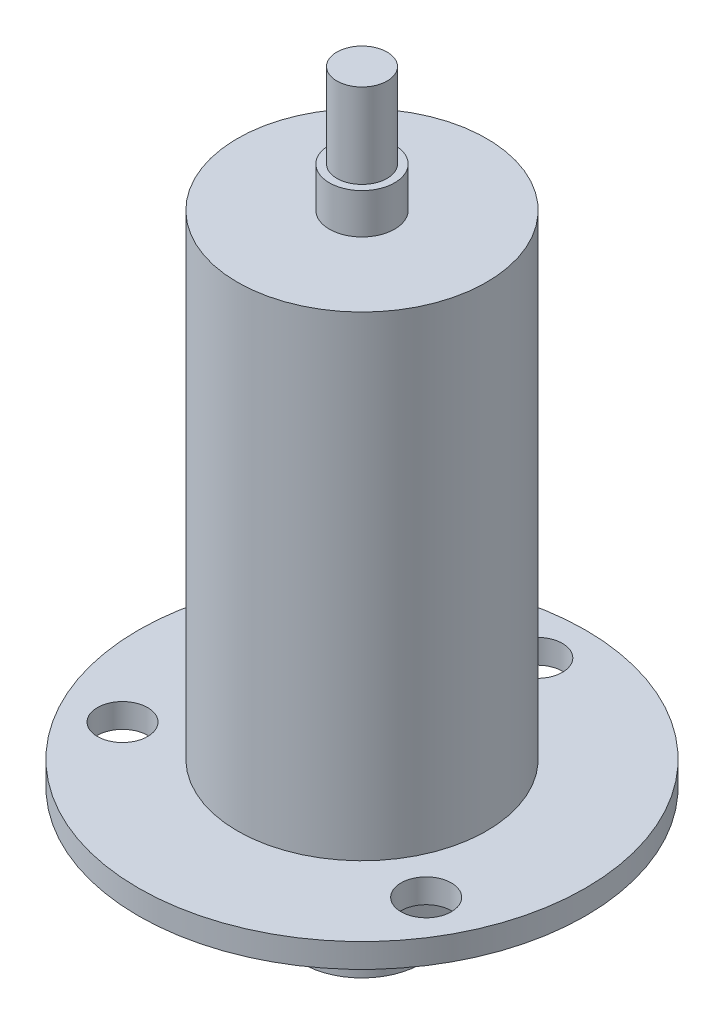
from build123d import *

# Parameters (mm, degrees)
SKETCH2_R           = 22.25
SKETCH2_R_2         = 2.5
BOSS_EXTRUDE1_DEPTH = 2.4
SKETCH3_R           = 12.4
BOSS_EXTRUDE2_DEPTH = 47.3
SKETCH4_R           = 3.25
BOSS_EXTRUDE3_DEPTH = 4
SKETCH5_R           = 2.5
BOSS_EXTRUDE4_DEPTH = 8.4
SKETCH6_R           = 12.385
BOSS_EXTRUDE5_DEPTH = 5.1
SKETCH7_R           = 5.9
BOSS_EXTRUDE6_DEPTH = 7.2


with BuildPart() as part:
    # Sketch2 → Boss-Extrude1 (new body)
    with BuildSketch(Plane(origin=(0, 0, 0), x_dir=(1, 0, 0), z_dir=(0, 1, 0))):
        Circle(SKETCH2_R)
        with Locations((0, 17.45)):
            Circle(SKETCH2_R_2, mode=Mode.SUBTRACT)
        with Locations((15.112143296, -8.725)):
            Circle(SKETCH2_R_2, mode=Mode.SUBTRACT)
        with Locations((-15.112143296, -8.725)):
            Circle(SKETCH2_R_2, mode=Mode.SUBTRACT)
    extrude(amount=BOSS_EXTRUDE1_DEPTH)

    # Sketch3 → Boss-Extrude2 (add)
    with BuildSketch(Plane(origin=(0, 2.4, 0), x_dir=(1, 0, 0), z_dir=(0, 1, 0))):
        Circle(SKETCH3_R)
    extrude(amount=BOSS_EXTRUDE2_DEPTH)

    # Sketch4 → Boss-Extrude3 (add)
    with BuildSketch(Plane(origin=(0, 49.7, 0), x_dir=(1, 0, 0), z_dir=(0, 1, 0))):
        Circle(SKETCH4_R)
    extrude(amount=BOSS_EXTRUDE3_DEPTH)

    # Sketch5 → Boss-Extrude4 (add)
    with BuildSketch(Plane(origin=(0, 53.7, 0), x_dir=(1, 0, 0), z_dir=(0, 1, 0))):
        Circle(SKETCH5_R)
    extrude(amount=BOSS_EXTRUDE4_DEPTH)

    # Sketch6 → Boss-Extrude5 (add)
    with BuildSketch(Plane.XZ):
        Circle(SKETCH6_R)
    extrude(amount=BOSS_EXTRUDE5_DEPTH)

    # Sketch7 → Boss-Extrude6 (add)
    with BuildSketch(Plane.XZ.offset(5.1)):
        Circle(SKETCH7_R)
    extrude(amount=BOSS_EXTRUDE6_DEPTH)


solid = part.part
